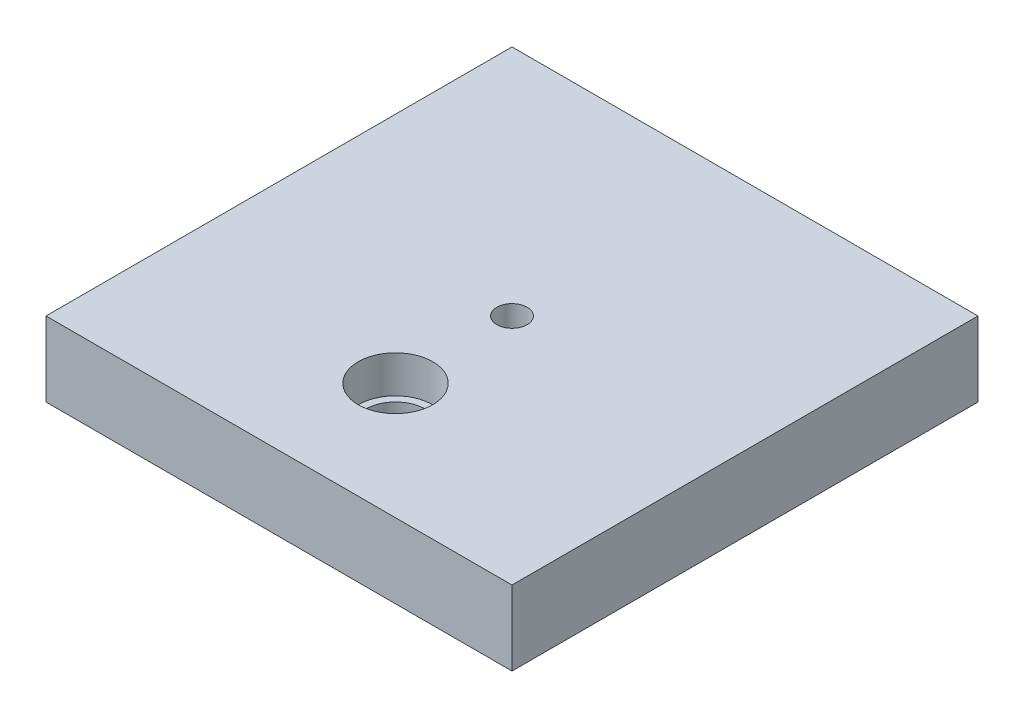
from build123d import *

# Parameters (mm, degrees)
SKETCH1_W           = 100
SKETCH1_H           = 100
SKETCH1_R           = 3.25
BOSS_EXTRUDE1_DEPTH = 16
SKETCH2_R           = 8
CUT_EXTRUDE1_DEPTH  = 8
CUT_EXTRUDE2_REACH  = 10
SKETCH3_R           = 6.4


with BuildPart() as part:
    # Sketch1 → Boss-Extrude1 (new body)
    with BuildSketch(Plane(origin=(0, 0, 0), x_dir=(1, 0, 0), z_dir=(0, 1, 0))):
        Rectangle(SKETCH1_W, SKETCH1_H)
        Circle(SKETCH1_R, mode=Mode.SUBTRACT)
    extrude(amount=BOSS_EXTRUDE1_DEPTH)

    # Sketch2 → Cut-Extrude1 (cut)
    with BuildSketch(Plane(origin=(0, 16, 0), x_dir=(1, 0, 0), z_dir=(0, 1, 0))):
        with Locations((0, -25)):
            Circle(SKETCH2_R)
    extrude(amount=-CUT_EXTRUDE1_DEPTH, mode=Mode.SUBTRACT)

    # Sketch3 → Cut-Extrude2 (cut, up to next)
    with BuildSketch(Plane(origin=(0, 8, 0), x_dir=(1, 0, 0), z_dir=(0, 1, 0)), mode=Mode.PRIVATE) as cut_extrude2_sk1:
        with Locations((0, -25)):
            Circle(SKETCH3_R)
    cut_extrude2_tool1 = extrude(cut_extrude2_sk1.sketch, amount=-CUT_EXTRUDE2_REACH, mode=Mode.PRIVATE) & part.part
    add(cut_extrude2_tool1.solids().sort_by_distance((0, 8, 25))[0], mode=Mode.SUBTRACT)


solid = part.part
